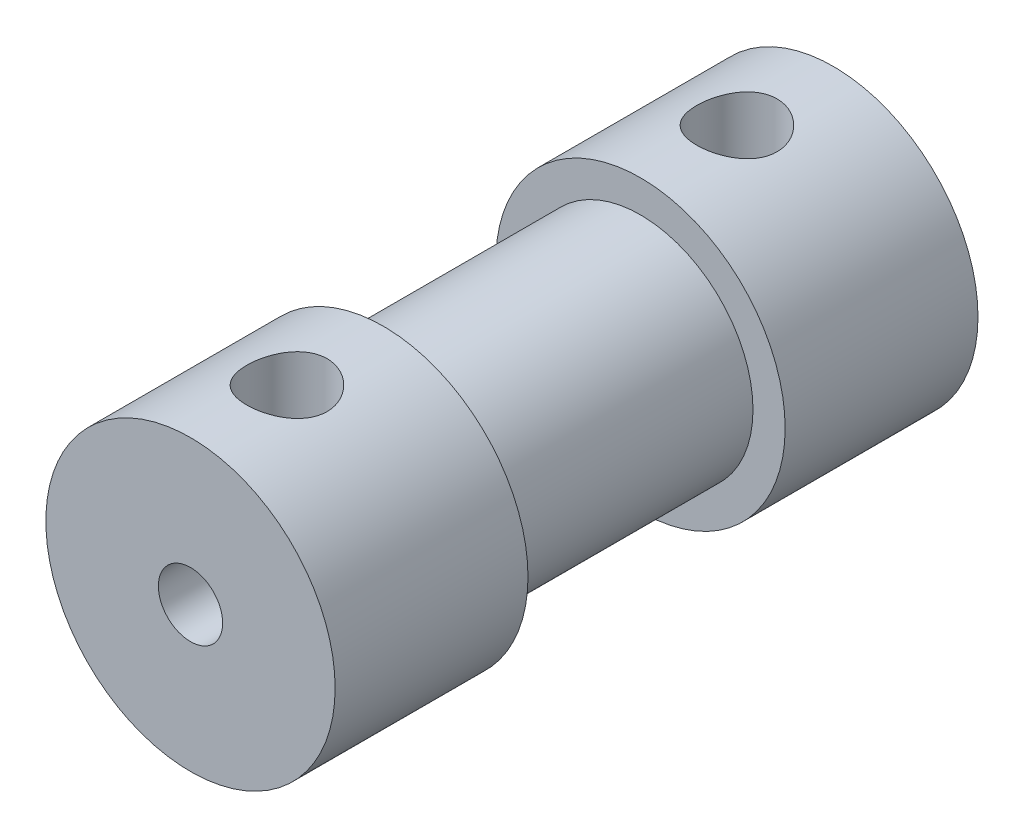
from build123d import *

# Parameters (mm, degrees)
BOSS_EXTRUDE1_DEPTH      = 10
BOSS_EXTRUDE1_DEPTH_BACK = 10
SKETCH1_R                = 4.5
CUT_EXTRUDE1_DEPTH       = 4
CUT_EXTRUDE1_DEPTH_BACK  = 4
SKETCH2_R                = 4.5
SKETCH2_R_2              = 3.5
SKETCH3_R                = 1
CUT_EXTRUDE2_DEPTH       = 20
SKETCH4_R                = 2
CUT_EXTRUDE3_DEPTH       = 12
CUT_EXTRUDE4_DEPTH       = 10
CUT_EXTRUDE4_DEPTH_BACK  = 10
SKETCH5_R                = 1.25


with BuildPart() as part:
    # Sketch1 → Boss-Extrude1 (new, two sides: drawn at the far end of the back side and taken through both)
    with BuildSketch(Plane.XY.offset(-BOSS_EXTRUDE1_DEPTH_BACK)):
        Circle(SKETCH1_R)
    extrude(amount=BOSS_EXTRUDE1_DEPTH + BOSS_EXTRUDE1_DEPTH_BACK)

    # Sketch2 → Cut-Extrude1 (cut, two sides: drawn at the far end of the back side and taken through both)
    with BuildSketch(Plane.XY.offset(-CUT_EXTRUDE1_DEPTH_BACK)):
        Circle(SKETCH2_R)
        Circle(SKETCH2_R_2, mode=Mode.SUBTRACT)
    extrude(amount=CUT_EXTRUDE1_DEPTH + CUT_EXTRUDE1_DEPTH_BACK, mode=Mode.SUBTRACT)

    # Sketch3 → Cut-Extrude2 (cut)
    with BuildSketch(Plane.XY.offset(10)):
        Circle(SKETCH3_R)
    extrude(amount=-CUT_EXTRUDE2_DEPTH, mode=Mode.SUBTRACT)

    # Sketch4 → Cut-Extrude3 (cut)
    with BuildSketch(Plane(origin=(0, 0, -10), x_dir=(-1, 0, 0), z_dir=(0, 0, -1))):
        Circle(SKETCH4_R)
    extrude(amount=-CUT_EXTRUDE3_DEPTH, mode=Mode.SUBTRACT)

    # Sketch5 → Cut-Extrude4 (cut, two sides: drawn at the far end of the back side and taken through both)
    with BuildSketch(Plane(origin=(0, 0, 0), x_dir=(1, 0, 0), z_dir=(0, 1, 0)).offset(-CUT_EXTRUDE4_DEPTH_BACK)):
        with Locations((0, 7)):
            Circle(SKETCH5_R)
        with Locations((0, -7)):
            Circle(SKETCH5_R)
    extrude(amount=CUT_EXTRUDE4_DEPTH + CUT_EXTRUDE4_DEPTH_BACK, mode=Mode.SUBTRACT)


solid = part.part
